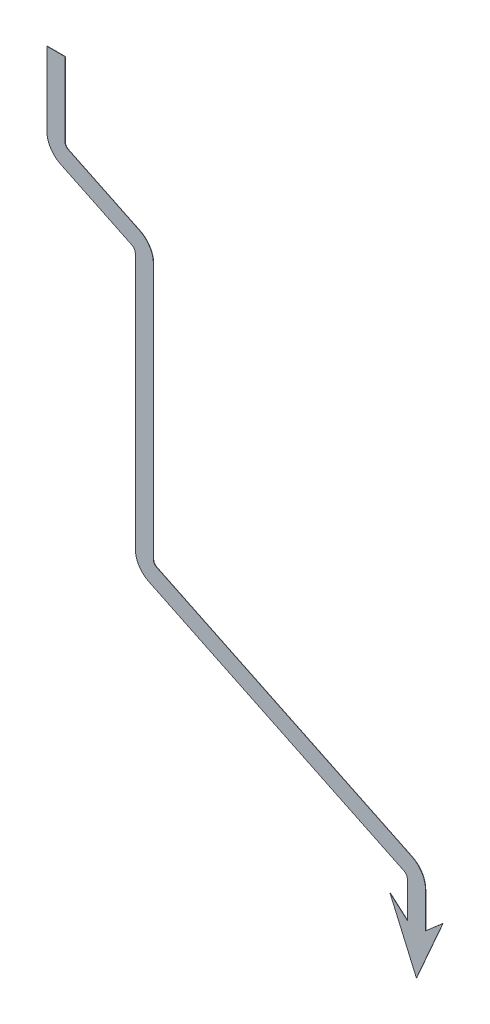
from build123d import *

# Parameters (mm, degrees)
EXTRU_MINCE1_DEPTH = 0.2
EXTRUSION1_DEPTH   = 0.2


with BuildPart() as part:
    # Esquisse2 → Extru.-Mince1 (new body)
    with BuildSketch(Plane.XY):
        with BuildLine():
            Line((-68.020160179, 174.136090676), (-68.020160179, 125.41885319))
            ThreePointArc((-68.020160179, 125.41885319), (-65.568146462, 116.906975155), (-58.963651719, 111.004002333))
            Line((-58.963651719, 111.004002333), (-11.723955687, 88.249106497))
            ThreePointArc((-11.723955686, 88.249106497), (-10.072832001, 86.773363292), (-9.459828571, 84.645393783))
            Line((-9.459828571, 84.645393783), (-9.459828571, -84.851832415))
            ThreePointArc((-9.459828571, -84.851832415), (-7.007814854, -93.36371045), (-0.403320111, -99.266683272))
            Line((-0.403320111, -99.266683272), (168.46168003, -180.607288974))
            ThreePointArc((168.46168003, -180.607288974), (170.112803715, -182.083032179), (170.725807145, -184.211001688))
            Line((170.725807145, -184.211001688), (170.725807145, -207.928239175))
            Line((170.725807145, -207.928239175), (182.725807145, -207.928239175))
            Line((182.725807145, -207.928239175), (182.725807145, -184.211001688))
            ThreePointArc((182.725807145, -184.211001688), (180.273793427, -175.699123653), (173.669298684, -169.796150831))
            Line((173.669298684, -169.796150831), (4.804298544, -88.455545129))
            ThreePointArc((4.804298544, -88.455545129), (3.153174858, -86.979801923), (2.540171429, -84.851832415))
            Line((2.540171429, -84.851832415), (2.540171429, 84.645393783))
            ThreePointArc((2.540171429, 84.645393783), (0.088157711, 93.157271818), (-6.516337032, 99.06024464))
            Line((-6.516337032, 99.06024464), (-53.756033064, 121.815140475))
            ThreePointArc((-53.756033064, 121.815140475), (-55.40715675, 123.290883681), (-56.020160179, 125.41885319))
            Line((-56.020160179, 125.41885319), (-56.020160179, 174.136090676))
            Line((-56.020160179, 174.136090676), (-68.020160179, 174.136090676))
        make_face()
    extrude(amount=EXTRU_MINCE1_DEPTH)

    # Esquisse3 → Extrusion1 (add)
    with BuildSketch(Plane(origin=(0, 0, 0), x_dir=(-1, 0, 0), z_dir=(0, 0, -1))):
        Polygon((-182.725807145, -207.928239175), (-194.225807145, -197.928239175), (-176.725807145, -237.928239175), (-159.225807145, -197.928239175), (-170.725807145, -207.928239175), align=None)
    extrude(amount=-EXTRUSION1_DEPTH)


solid = part.part
